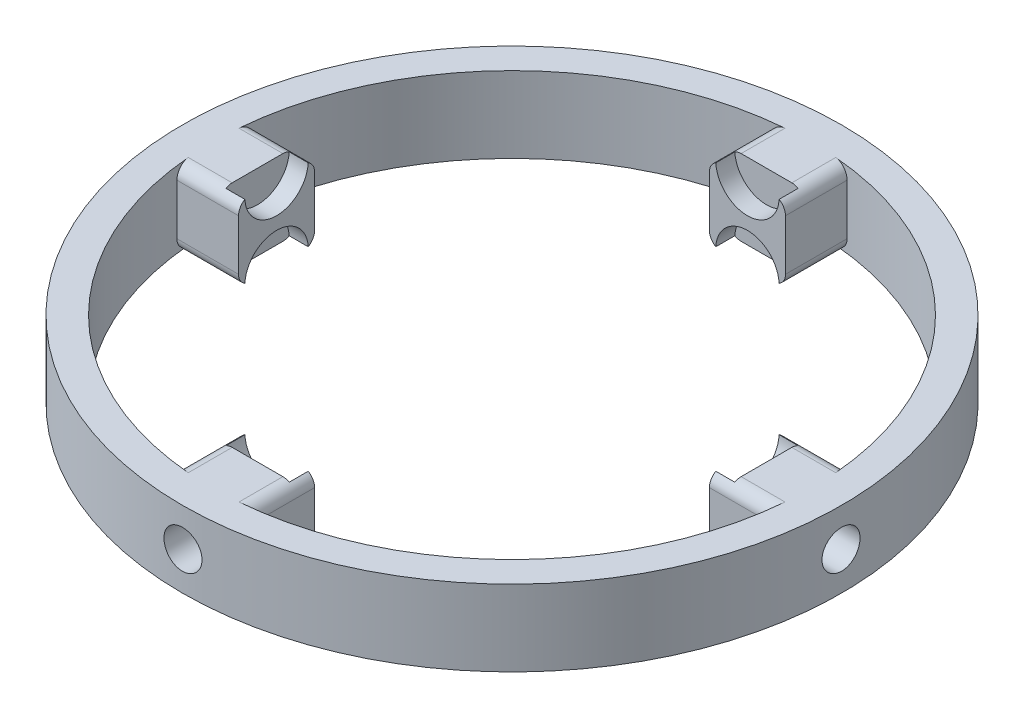
from build123d import *

# Parameters (mm, degrees)
SKETCH1_R           = 26
SKETCH1_R_2         = 23.625
BOSS_EXTRUDE1_DEPTH = 6
SKETCH2_W           = 7.25
SKETCH2_H           = 6
BOSS_EXTRUDE2_DEPTH = 6
CIRPATTERN1_COUNT   = 4
SKETCH3_R           = 2.5
CUT_EXTRUDE1_DEPTH  = 1.5
CIRPATTERN2_COUNT   = 4
FILLET1_R           = 1
SKETCH4_R           = 1.5
CUT_EXTRUDE2_DEPTH  = 4
CIRPATTERN4_COUNT   = 4


with BuildPart() as part:
    # Sketch1 → Boss-Extrude1 (new body)
    with BuildSketch(Plane(origin=(0, 0, 0), x_dir=(1, 0, 0), z_dir=(0, 1, 0))):
        Circle(SKETCH1_R)
        Circle(SKETCH1_R_2, mode=Mode.SUBTRACT)
    extrude(amount=BOSS_EXTRUDE1_DEPTH)

    # Sketch2 → Boss-Extrude2 (add)
    with BuildSketch(Plane(origin=(0, 6, 0), x_dir=(1, 0, 0), z_dir=(0, 1, 0))):
        with Locations((-22.20134314, 0)):
            Rectangle(SKETCH2_W, SKETCH2_H)
    boss_extrude2 = extrude(amount=-BOSS_EXTRUDE2_DEPTH)

    # CirPattern1: Boss-Extrude2 ×4 about axis
    cirpattern1_axis = Axis((0, 0, 0), (0, 1, 0))
    for i in range(1, CIRPATTERN1_COUNT):
        add(boss_extrude2.rotate(cirpattern1_axis, i * 360 / CIRPATTERN1_COUNT))

    # Sketch3 → Cut-Extrude1 (cut)
    with BuildSketch(Plane(origin=(-18.57634314, 0, 0), x_dir=(0, 0, -1), z_dir=(1, 0, 0))):
        with Locations((0, 6)):
            Circle(SKETCH3_R)
        Circle(SKETCH3_R)
    cut_extrude1 = extrude(amount=-CUT_EXTRUDE1_DEPTH, mode=Mode.SUBTRACT)

    # CirPattern2: Cut-Extrude1 ×4 about axis
    cirpattern2_axis = Axis((0, 0, 0), (0, 1, 0))
    for i in range(1, CIRPATTERN2_COUNT):
        add(cut_extrude1.rotate(cirpattern2_axis, i * 360 / CIRPATTERN2_COUNT), mode=Mode.SUBTRACT)

    # Fillet1
    fillet1_edges = [part.edges().sort_by_distance(p)[0] for p in [
        (-21.00504642, 6, 3),
        (-21.00504642, 6, -3),
        (-21.00504642, 0, -3),
        (-21.00504642, 0, 3),
        (3, 6, 21.00504642),
        (-3, 6, 21.00504642),
        (-3, 0, 21.00504642),
        (3, 0, 21.00504642),
        (21.00504642, 6, -3),
        (21.00504642, 6, 3),
        (21.00504642, 0, 3),
        (21.00504642, 0, -3),
        (-3, 6, -21.00504642),
        (3, 6, -21.00504642),
        (3, 0, -21.00504642),
        (-3, 0, -21.00504642),
    ]]
    fillet(fillet1_edges, radius=FILLET1_R)

    # Sketch4 → Cut-Extrude2 (cut)
    with BuildSketch(Plane.XY.offset(26)):
        with Locations((0, 3)):
            Circle(SKETCH4_R)
    cut_extrude2 = extrude(amount=-CUT_EXTRUDE2_DEPTH, mode=Mode.SUBTRACT)

    # CirPattern4: Cut-Extrude2 ×4 about axis
    cirpattern4_axis = Axis((0, 0, 0), (0, 1, 0))
    for i in range(1, CIRPATTERN4_COUNT):
        add(cut_extrude2.rotate(cirpattern4_axis, i * 360 / CIRPATTERN4_COUNT), mode=Mode.SUBTRACT)


solid = part.part
